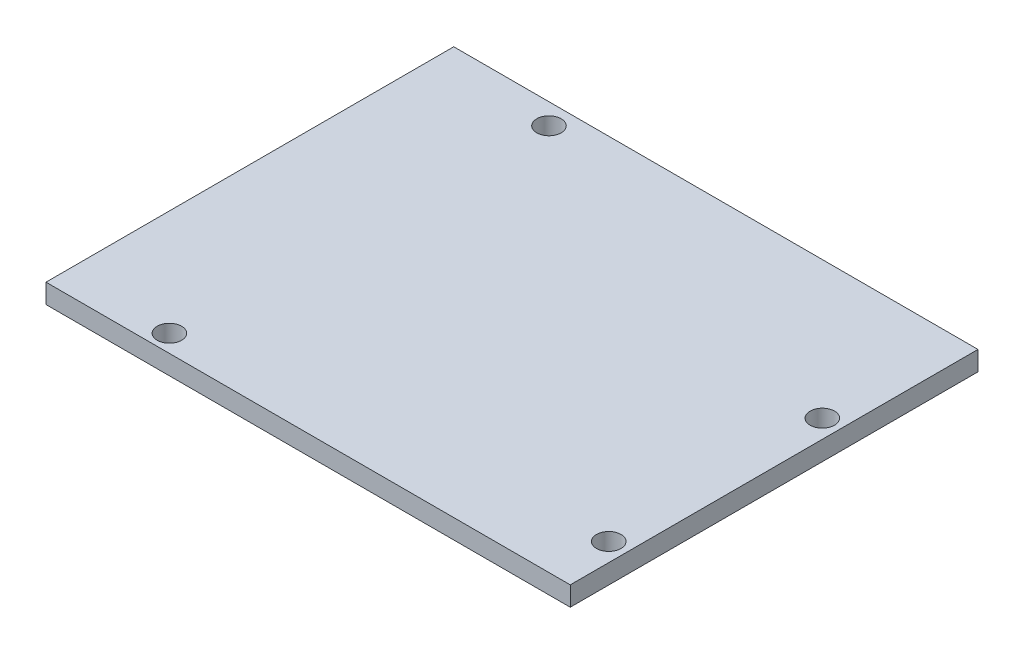
from build123d import *

# Parameters (mm, degrees)
SKETCH1_W                = 68.58
SKETCH1_H                = 53.34
BOSS_EXTRUDE1_DEPTH      = 2.54
M3_CLEARANCE_HOLE1_D     = 3.2
M3_CLEARANCE_HOLE1_DEPTH = 5.08
M3_CLEARANCE_HOLE1_TIP   = 0.96137699


with BuildPart() as part:
    # Sketch1 → Boss-Extrude1 (new body)
    with BuildSketch(Plane(origin=(0, 0, 0), x_dir=(1, 0, 0), z_dir=(0, 1, 0))):
        with Locations((-1.769700695, -0.9496024)):
            Rectangle(SKETCH1_W, SKETCH1_H)
    extrude(amount=BOSS_EXTRUDE1_DEPTH)

    # M3 Clearance Hole1
    with Locations(Plane(origin=(0, 2.54, 0), x_dir=(-1, 0, 0), z_dir=(0, 1, 0))):
        with Locations((-30.125330134, -7.752375477), (-30.125330134, 20.187624523), (22.198669866, 25.335357903), (20.874669866, -22.992375477)):
            Hole(M3_CLEARANCE_HOLE1_D / 2, depth=M3_CLEARANCE_HOLE1_DEPTH)
            with Locations((0, 0, -(M3_CLEARANCE_HOLE1_DEPTH + M3_CLEARANCE_HOLE1_TIP / 2))):  # 118° drill point
                Cone(0, M3_CLEARANCE_HOLE1_D / 2, M3_CLEARANCE_HOLE1_TIP, mode=Mode.SUBTRACT)


solid = part.part
